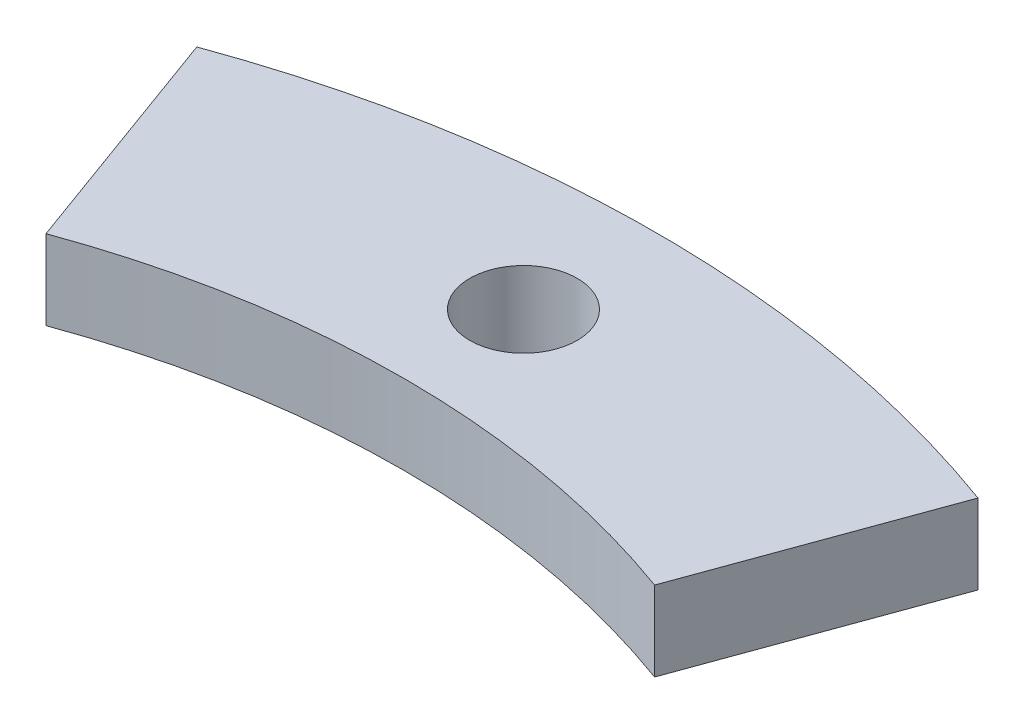
from build123d import *

# Parameters (mm, degrees)
SKETCH1_R               = 43
SKETCH1_R_2             = 33.5
BOSS_EXTRUDE1_DEPTH     = 3
CUT_EXTRUDE1_START      = -4
CUT_EXTRUDE1_DEPTH      = 5
SKETCH3_R               = 2.025
CUT_EXTRUDE2_DEPTH      = 1
CUT_EXTRUDE2_DEPTH_BACK = 4


with BuildPart() as part:
    # Sketch1 → Boss-Extrude1 (new body)
    with BuildSketch(Plane(origin=(0, 0, 0), x_dir=(1, 0, 0), z_dir=(0, 1, 0))):
        Circle(SKETCH1_R)
        Circle(SKETCH1_R_2, mode=Mode.SUBTRACT)
    extrude(amount=BOSS_EXTRUDE1_DEPTH)

    # Sketch2 → Cut-Extrude1 (cut)
    with BuildSketch(Plane(origin=(0, 3, 0), x_dir=(1, 0, 0), z_dir=(0, 1, 0)).offset(CUT_EXTRUDE1_START)):
        with BuildLine():
            Line((0, 0), (0, -52.31984462))
            ThreePointArc((0, -52.31984462), (51.524988618, -9.085245674), (17.894440756, 49.16457191))
            Line((17.894440756, 49.16457191), (0, 0))
        make_face()
    cut_extrude1 = extrude(amount=CUT_EXTRUDE1_DEPTH, mode=Mode.SUBTRACT)

    # Mirror1: Cut-Extrude1 across plane
    add(cut_extrude1.mirror(Plane(origin=(0, 0, 0), x_dir=(0, 0, 1), z_dir=(1, 0, 0))), mode=Mode.SUBTRACT)

    # Sketch3 → Cut-Extrude2 (cut, two sides)
    with BuildSketch(Plane(origin=(0, 3, 0), x_dir=(1, 0, 0), z_dir=(0, 1, 0))) as cut_extrude2_sk:
        with Locations((0, 38)):
            Circle(SKETCH3_R)
    extrude(amount=CUT_EXTRUDE2_DEPTH, mode=Mode.SUBTRACT)
    extrude(cut_extrude2_sk.sketch, amount=-CUT_EXTRUDE2_DEPTH_BACK, mode=Mode.SUBTRACT)


solid = part.part
